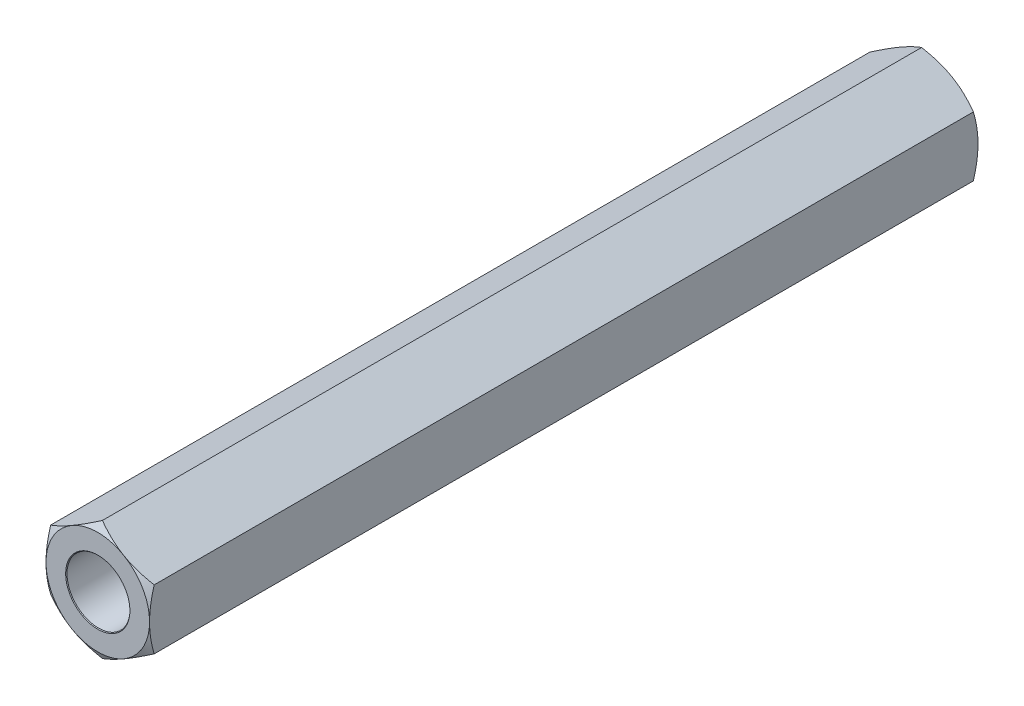
from build123d import *

# Parameters (mm, degrees)
EXTRUDE1_DEPTH          = 31.75
EXTRUDE1_DEPTH_BACK     = 31.75
SKETCH1_R               = 2.413
SKETCH8_OUTSIDE_W       = 247.302
SKETCH8_OUTSIDE_H       = 248.53
SKETCH8_OUTSIDE_R       = 3.96875
EXTRUDE4_DEPTH          = 64.788731596
EXTRUDE4_DRAFT          = -60
MIRROR1_COPY_1_SKETCH_W = 247.302
MIRROR1_COPY_1_SKETCH_H = 248.53
MIRROR1_COPY_1_SKETCH_R = 3.96875
MIRROR1_COPY_1_DEPTH    = 64.788731596
MIRROR1_COPY_1_DRAFT    = -60
SKETCH9_W               = 38.1
SKETCH9_H               = 2.4638


with BuildPart() as part:
    # Sketch1 → Extrude1 (new, two sides: drawn at the far end of the back side and taken through both)
    with BuildSketch(Plane.XY.offset(-EXTRUDE1_DEPTH_BACK)):
        Polygon((0, 4.582717762), (-3.96875, 2.291358881), (-3.96875, -2.291358881), (0, -4.582717762), (3.96875, -2.291358881), (3.96875, 2.291358881), align=None)
        Circle(SKETCH1_R, mode=Mode.SUBTRACT)
    extrude(amount=EXTRUDE1_DEPTH + EXTRUDE1_DEPTH_BACK)

    # Extrude3 cone 1 section (through the dimple's axis) → Extrude3 (revolve, cut)
    with BuildSketch(Plane(origin=(0, 0, -31.75), x_dir=(0, 1, 0), z_dir=(1, 0, 0))):
        Polygon((0, 0), (2.4638, 0), (0, 2.642102028), align=None)
    extrude3 = revolve(axis=Axis((0, 0, -31.75), (0, 0, 1)), mode=Mode.SUBTRACT)


with BuildPart() as extrude4_tool:
    # Sketch8 outside → Extrude4 (with draft: the straight prism first)
    with BuildSketch(Plane(origin=(0, 0, -31.75), x_dir=(-1, 0, 0), z_dir=(0, 0, -1))):
        Rectangle(SKETCH8_OUTSIDE_W, SKETCH8_OUTSIDE_H)
        Circle(SKETCH8_OUTSIDE_R, mode=Mode.SUBTRACT)
    extrude(amount=-EXTRUDE4_DEPTH)
    # Extrude4: the draft: its side faces are tilted about the plane it starts from
    extrude4_sides = [extrude4_tool.faces().sort_by_distance(p)[0] for p in [
        (0, -124.265, 0.644365798),
        (-123.651, 0, 0.644365798),
        (0, 124.265, 0.644365798),
        (123.651, 0, 0.644365798),
        (3.96875, 0, 0.644365798),
    ]]
    draft(extrude4_sides, Plane(origin=(0, 0, -31.75), x_dir=(-1, 0, 0), z_dir=(0, 0, -1)), EXTRUDE4_DRAFT)


with BuildPart() as part_1:
    add(part.part)

    # Extrude4: cut by extrude4_tool
    add(extrude4_tool.part, mode=Mode.SUBTRACT)

    # Mirror1: Extrude3 across plane
    add(extrude3.mirror(Plane.XY), mode=Mode.SUBTRACT)


with BuildPart() as mirror1_copy_1_tool:
    # Mirror1 copy 1 sketch → Mirror1 copy 1 (with draft: the straight prism first)
    with BuildSketch(Plane(origin=(0, 0, 31.75), x_dir=(-1, 0, 0), z_dir=(0, 0, 1))):
        Rectangle(MIRROR1_COPY_1_SKETCH_W, MIRROR1_COPY_1_SKETCH_H)
        Circle(MIRROR1_COPY_1_SKETCH_R, mode=Mode.SUBTRACT)
    extrude(amount=-MIRROR1_COPY_1_DEPTH)
    # Mirror1 copy 1: the draft: its side faces are tilted about the plane it starts from
    mirror1_copy_1_sides = [mirror1_copy_1_tool.faces().sort_by_distance(p)[0] for p in [
        (0, -124.265, -0.644365798),
        (-123.651, 0, -0.644365798),
        (0, 124.265, -0.644365798),
        (123.651, 0, -0.644365798),
        (3.96875, 0, -0.644365798),
    ]]
    draft(mirror1_copy_1_sides, Plane(origin=(0, 0, 31.75), x_dir=(-1, 0, 0), z_dir=(0, 0, 1)), MIRROR1_COPY_1_DRAFT)


with BuildPart() as part_2:
    add(part_1.part)

    # Mirror1 copy 1: cut by mirror1_copy_1_tool
    add(mirror1_copy_1_tool.part, mode=Mode.SUBTRACT)

    # Sketch9 → Revolve 2 (revolve)
    with BuildSketch(Plane(origin=(0, 0, 0), x_dir=(0, 0, -1), z_dir=(1, 0, 0)), mode=Mode.PRIVATE) as revolve_2_sk:
        with Locations((0, 1.2319)):
            Rectangle(SKETCH9_W, SKETCH9_H)
    revolve(revolve_2_sk.sketch.rotate(Axis((0, 0, 31.75), (0, 0, -1)), 270), axis=Axis((0, 0, 31.75), (0, 0, -1)))


solid = part_2.part
